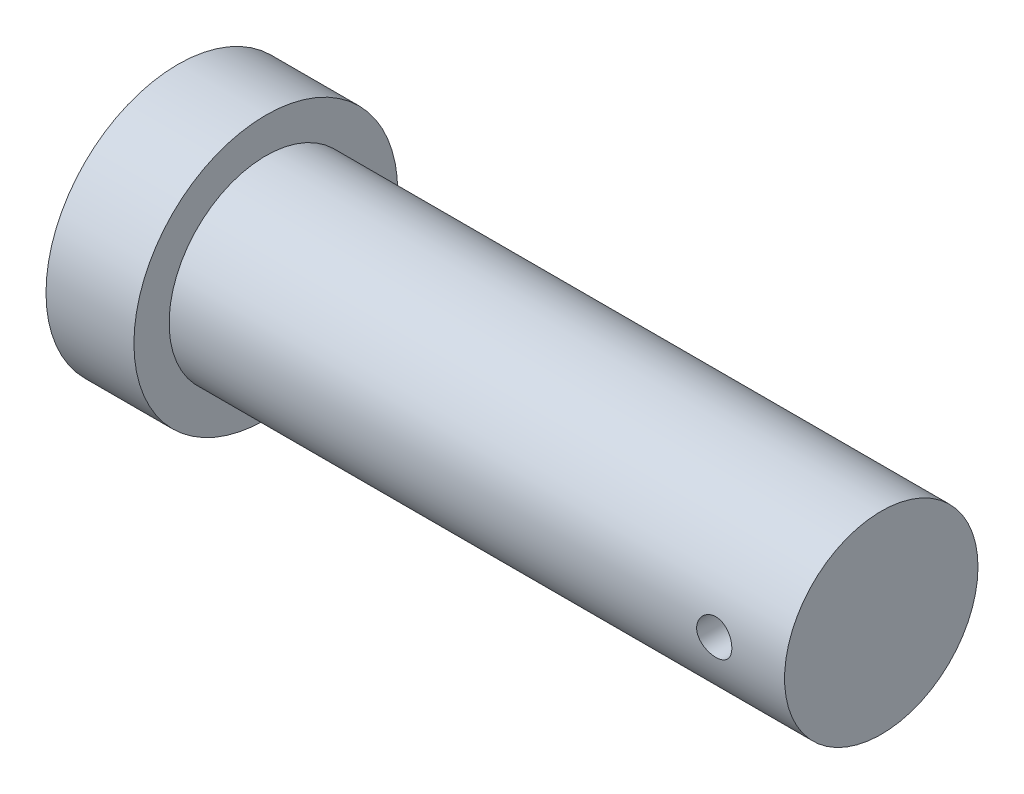
from build123d import *

# Parameters (mm, degrees)
SKETCH1_R               = 5.5
BOSS_EXTRUDE1_DEPTH     = 35
SKETCH2_R               = 7.5
BOSS_EXTRUDE2_DEPTH     = 5
SKETCH3_R               = 1
CUT_EXTRUDE1_DEPTH      = 8.5
CUT_EXTRUDE1_DEPTH_BACK = 8.5


with BuildPart() as part:
    # Sketch1 → Boss-Extrude1 (new body)
    with BuildSketch(Plane(origin=(0, 0, 0), x_dir=(0, 0, -1), z_dir=(1, 0, 0))):
        Circle(SKETCH1_R)
    extrude(amount=-BOSS_EXTRUDE1_DEPTH)

    # Sketch2 → Boss-Extrude2 (add)
    with BuildSketch(Plane.ZY.offset(35)):
        Circle(SKETCH2_R)
    extrude(amount=BOSS_EXTRUDE2_DEPTH)

    # Sketch3 → Cut-Extrude1 (cut, two sides)
    with BuildSketch(Plane.XY) as cut_extrude1_sk:
        with Locations((-4, 0)):
            Circle(SKETCH3_R)
    extrude(amount=CUT_EXTRUDE1_DEPTH, mode=Mode.SUBTRACT)
    extrude(cut_extrude1_sk.sketch, amount=-CUT_EXTRUDE1_DEPTH_BACK, mode=Mode.SUBTRACT)


solid = part.part
